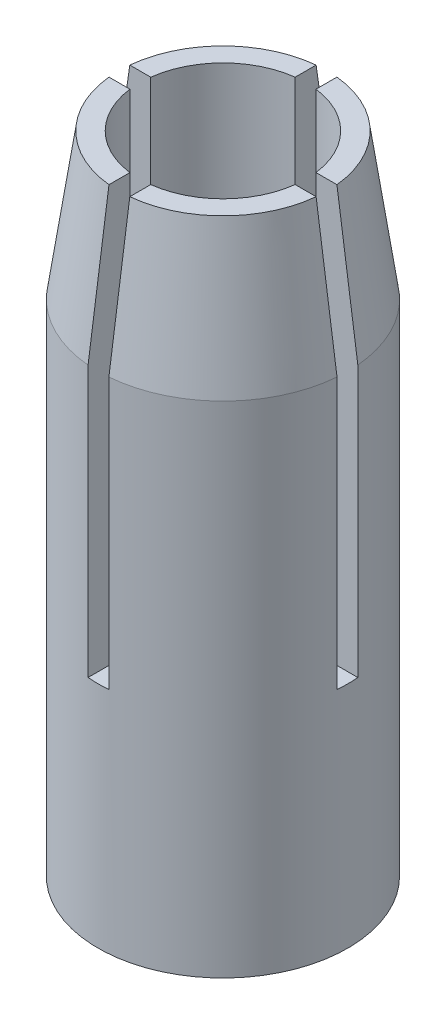
from build123d import *

# Parameters (mm, degrees)
CUT_EXTRUDE_1_DEPTH = 10
SKETCH_3_R          = 2
CUT_EXTRUDE_2_DEPTH = 16.5


with BuildPart() as part:
    # Эскиз1 → Повернуть1 (revolve)
    with BuildSketch(Plane.XY):
        Polygon((0, 15.5), (2.5, 15.5), (3, 12), (3, 0), (0, 0), align=None)
    revolve(axis=Axis((0, 0, 0), (0, 1, 0)))

    # Эскиз2 → Вырез-Вытянуть1 (cut)
    with BuildSketch(Plane(origin=(0, 15.5, 0), x_dir=(1, 0, 0), z_dir=(0, 1, 0))):
        Polygon((-0.25, 6.25), (0.25, 6.25), (0.25, 0.25), (6.25, 0.25), (6.25, -0.25), (0.25, -0.25), (0.25, -6.25), (-0.25, -6.25), (-0.25, -0.25), (-6.25, -0.25), (-6.25, 0.25), (-0.25, 0.25), align=None)
    extrude(amount=-CUT_EXTRUDE_1_DEPTH, mode=Mode.SUBTRACT)

    # Эскиз3 → Вырез-Вытянуть2 (cut, through all)
    with BuildSketch(Plane.XZ):
        Circle(SKETCH_3_R)
    extrude(amount=-CUT_EXTRUDE_2_DEPTH, mode=Mode.SUBTRACT)


solid = part.part
